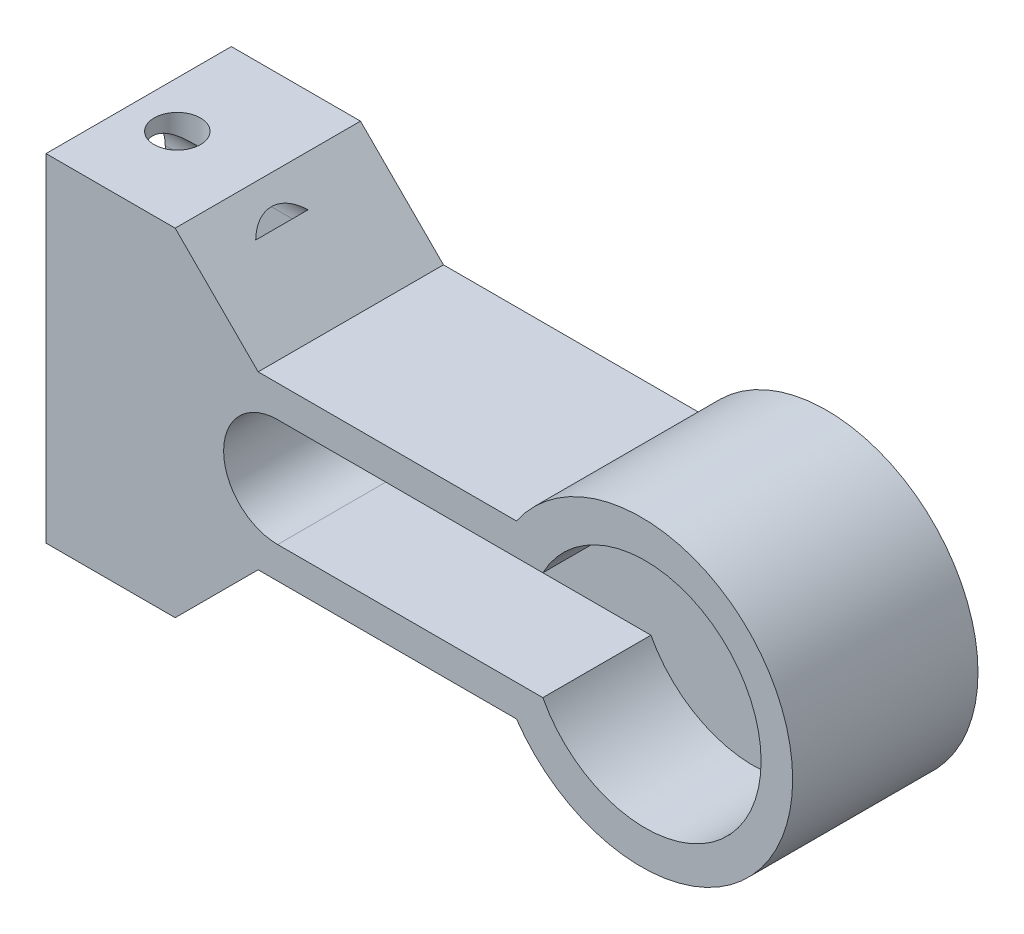
from build123d import *

# Parameters (mm, degrees)
SKETCH1_W           = 50
SKETCH1_H           = 30
BOSS_EXTRUDE1_DEPTH = 15
SKETCH2_R           = 4.5
CUT_EXTRUDE1_DEPTH  = 10
SKETCH4_R           = 7.5
CUT_EXTRUDE3_DEPTH  = 10
SKETCH5_R           = 1.25
CUT_EXTRUDE4_DEPTH  = 10
SKETCH7_W           = 50
SKETCH7_H           = 30
CUT_EXTRUDE5_DEPTH  = 3
CUT_EXTRUDE6_DEPTH  = 13
SKETCH9_R           = 1.5
CUT_EXTRUDE7_DEPTH  = 23


with BuildPart() as part:
    # Sketch1 → Boss-Extrude1 (new body)
    with BuildSketch(Plane.XY):
        Rectangle(SKETCH1_W, SKETCH1_H)
    extrude(amount=BOSS_EXTRUDE1_DEPTH)

    # Sketch2 → Cut-Extrude1 (cut)
    with BuildSketch(Plane.ZY.offset(25)):
        with Locations((6.728688525, -0.205173042)):
            Circle(SKETCH2_R)
        with BuildLine():
            Line((9.178688525, 7.516794171), (9.178688525, -7.927140255))
            ThreePointArc((9.178688525, -7.927140255), (6.728688525, -10.377140255), (4.278688525, -7.927140255))
            Line((4.278688525, -7.927140255), (4.278688525, 7.516794171))
            ThreePointArc((4.278688525, 7.516794171), (6.728688525, 9.966794171), (9.178688525, 7.516794171))
        make_face()
    extrude(amount=-CUT_EXTRUDE1_DEPTH, mode=Mode.SUBTRACT)

    # Sketch4 → Cut-Extrude3 (cut)
    with BuildSketch(Plane.XY.offset(15)):
        with Locations((13.8, 0)):
            Circle(SKETCH4_R)
        with BuildLine():
            Line((-10, 3.5), (13.8, 3.5))
            ThreePointArc((13.8, 3.5), (17.3, 0), (13.8, -3.5))
            Line((13.8, -3.5), (-10, -3.5))
            ThreePointArc((-10, -3.5), (-13.5, 0), (-10, 3.5))
        make_face()
    extrude(amount=-CUT_EXTRUDE3_DEPTH, mode=Mode.SUBTRACT)

    # Sketch5 → Cut-Extrude4 (cut)
    with BuildSketch(Plane.XY.offset(5)):
        with Locations((-10.053055142, 0)):
            Circle(SKETCH5_R)
        with Locations((-6.053055142, 0)):
            Circle(SKETCH5_R)
    extrude(amount=-CUT_EXTRUDE4_DEPTH, mode=Mode.SUBTRACT)

    # Sketch7 → Cut-Extrude5 (cut)
    with BuildSketch(Plane.XY.offset(15)):
        Rectangle(SKETCH7_W, SKETCH7_H)
    extrude(amount=-CUT_EXTRUDE5_DEPTH, mode=Mode.SUBTRACT)

    # Sketch8 → Cut-Extrude6 (cut)
    with BuildSketch(Plane.XY.offset(12)):
        with BuildLine():
            Line((-25, 15), (-25, 10.92225852))
            Line((-25, 10.92225852), (-16.637103876, 10.92225852))
            Line((-16.637103876, 10.92225852), (-11.26502882, 5.550183464))
            Line((-11.26502882, 5.550183464), (5.459842894, 5.550183464))
            ThreePointArc((5.459842894, 5.550183464), (23.343165243, 0), (5.459842894, -5.550183464))
            Line((5.459842894, -5.550183464), (-11.26502882, -5.550183464))
            Line((-11.26502882, -5.550183464), (-16.637103876, -10.92225852))
            Line((-16.637103876, -10.92225852), (-25, -10.92225852))
            Line((-25, -10.92225852), (-25, -15))
            Line((-25, -15), (25, -15))
            Line((25, -15), (25, 15))
            Line((25, 15), (-25, 15))
        make_face()
    extrude(amount=-CUT_EXTRUDE6_DEPTH, mode=Mode.SUBTRACT)

    # Sketch9 → Cut-Extrude7 (cut)
    with BuildSketch(Plane(origin=(0, 10.92225852, 0), x_dir=(1, 0, 0), z_dir=(0, 1, 0))):
        with Locations((-22, -6.5)):
            Circle(SKETCH9_R)
    extrude(amount=-CUT_EXTRUDE7_DEPTH, mode=Mode.SUBTRACT)


solid = part.part
